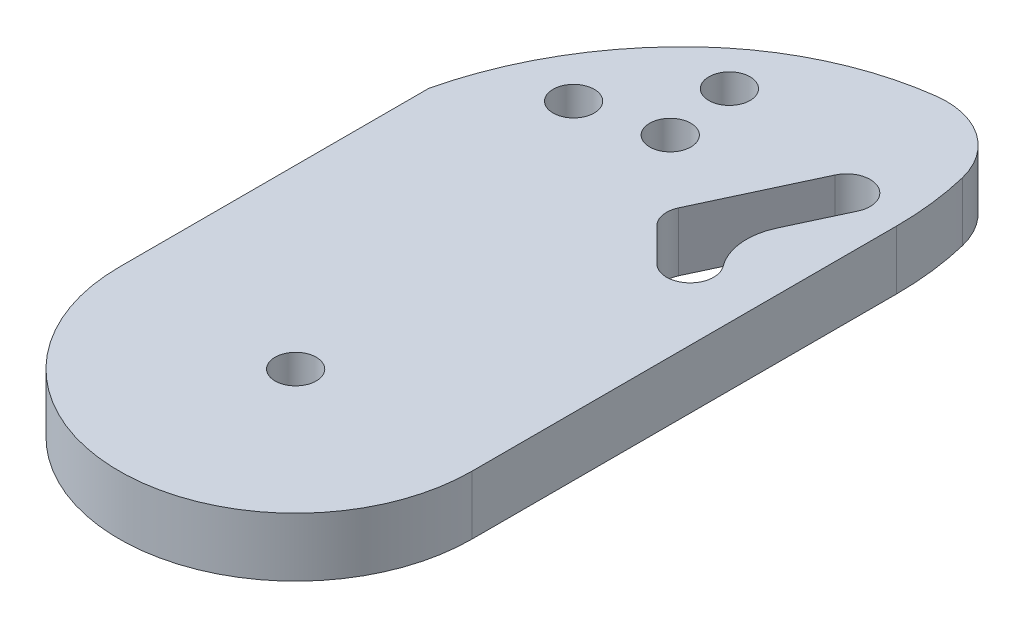
from build123d import *

# Parameters (mm, degrees)
SKETCH1_R           = 1.75
BOSS_EXTRUDE1_DEPTH = 5
FILLET1_R           = 5
CUT_EXTRUDE1_DEPTH  = 10
SKETCH3_R           = 1.75
CUT_EXTRUDE2_DEPTH  = 10


with BuildPart() as part:
    # Sketch1 → Boss-Extrude1 (new body)
    with BuildSketch(Plane(origin=(0, 0, 0), x_dir=(1, 0, 0), z_dir=(0, 1, 0))):
        with BuildLine():
            Line((-15, 0), (-15, 50))
            ThreePointArc((-15, 50), (0, 65), (15, 50))
            Line((15, 50), (15, 0))
            ThreePointArc((15, 0), (0, -15), (-15, 0))
        make_face()
        Circle(SKETCH1_R, mode=Mode.SUBTRACT)
        with BuildLine():
            Line((12.25773045, 35.509501863), (8.623388818, 27.715631082))
            Line((8.623388818, 27.715631082), (10.414213562, 25.924806337))
            ThreePointArc((10.414213562, 25.924806337), (10.414213562, 23.096379213), (7.585786438, 23.096379213))
            Line((7.585786438, 23.096379213), (4.804718696, 25.877446954))
            ThreePointArc((4.804718696, 25.877446954), (4.249316753, 26.944364161), (4.406316685, 28.13689704))
            Line((4.406316685, 28.13689704), (8.632499302, 37.19997491))
            ThreePointArc((8.632499302, 37.19997491), (11.2903514, 38.167353961), (12.25773045, 35.509501863))
        make_face(mode=Mode.SUBTRACT)
    extrude(amount=BOSS_EXTRUDE1_DEPTH)

    # Fillet1
    fillet1_edges = [part.edges().sort_by_distance(p)[0] for p in [
        (8.623388818, 2.5, -27.715631082),
    ]]
    fillet(fillet1_edges, radius=FILLET1_R)

    # Sketch2 → Cut-Extrude1 (cut)
    with BuildSketch(Plane(origin=(0, 5, 0), x_dir=(1, 0, 0), z_dir=(0, 1, 0))):
        with BuildLine():
            Line((-15, 26.324644949), (-40.925594741, 69.238213195))
            Line((-40.925594741, 69.238213195), (-58.771967888, 111.080687023))
            Line((-58.771967888, 111.080687023), (39.28439299, 102.825794629))
            Line((39.28439299, 102.825794629), (15, 36.046990739))
            ThreePointArc((15, 36.046990739), (14.81014445, 39.245839168), (14.243243524, 42.399773179))
            ThreePointArc((14.243243524, 42.399773179), (11.621838426, 46.208407589), (7.127072402, 47.292169164))
            ThreePointArc((7.127072402, 47.292169164), (-0.175202385, 45.163669538), (-6.484026655, 40.9148504))
            ThreePointArc((-6.484026655, 40.9148504), (-11.826766868, 34.252893813), (-15, 26.324644949))
        make_face()
    extrude(amount=-CUT_EXTRUDE1_DEPTH, mode=Mode.SUBTRACT)

    # Sketch3 → Cut-Extrude2 (cut)
    with BuildSketch(Plane(origin=(0, 5, 0), x_dir=(1, 0, 0), z_dir=(0, 1, 0))):
        with Locations((-1.301778952, 33.126107378)):
            Circle(SKETCH3_R)
        with Locations((-2.207127715, 39.057409395)):
            Circle(SKETCH3_R)
        with Locations((-7.905919506, 31.519764857)):
            Circle(SKETCH3_R)
    extrude(amount=-CUT_EXTRUDE2_DEPTH, mode=Mode.SUBTRACT)


solid = part.part
